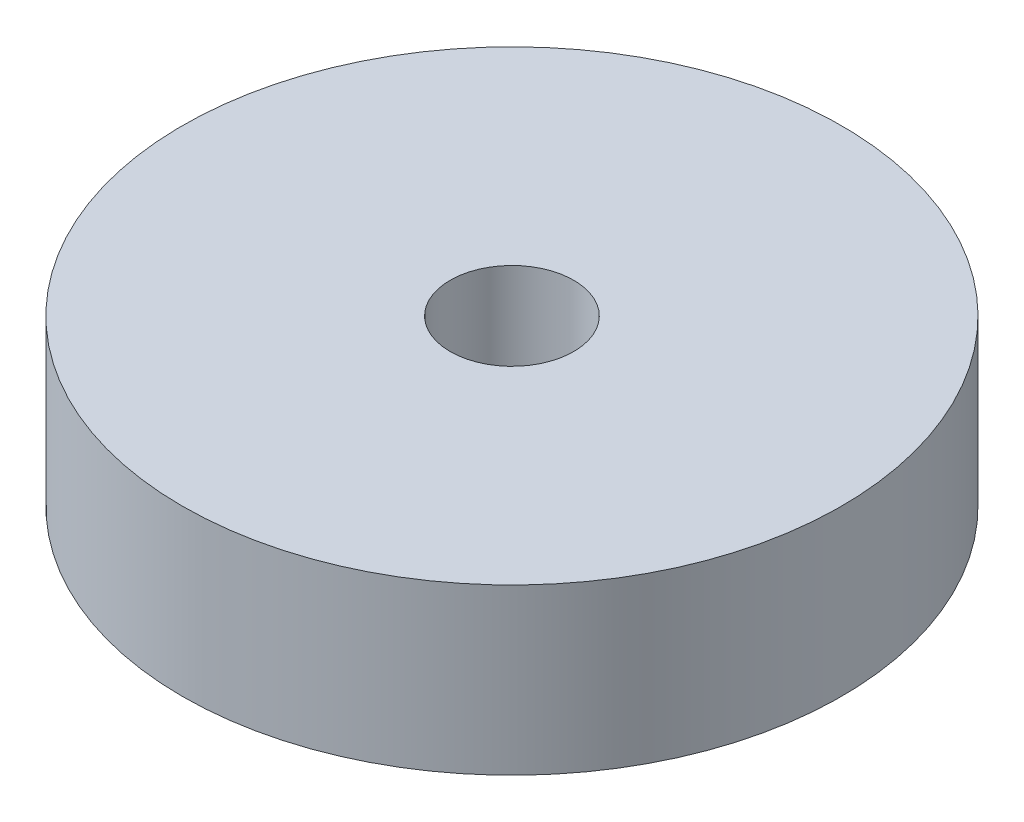
from build123d import *

# Parameters (mm, degrees)
SKETCH1_R               = 20
BOSS_EXTRUDE1_DEPTH     = 10
SKETCH2_R               = 3.75
CUT_EXTRUDE1_DEPTH      = 1
CUT_EXTRUDE1_DEPTH_BACK = 11


with BuildPart() as part:
    # Sketch1 → Boss-Extrude1 (new body)
    with BuildSketch(Plane(origin=(0, 0, 0), x_dir=(1, 0, 0), z_dir=(0, 1, 0))):
        Circle(SKETCH1_R)
    extrude(amount=BOSS_EXTRUDE1_DEPTH)

    # Sketch2 → Cut-Extrude1 (cut, two sides)
    with BuildSketch(Plane(origin=(0, 10, 0), x_dir=(1, 0, 0), z_dir=(0, 1, 0))) as cut_extrude1_sk:
        Circle(SKETCH2_R)
    extrude(amount=CUT_EXTRUDE1_DEPTH, mode=Mode.SUBTRACT)
    extrude(cut_extrude1_sk.sketch, amount=-CUT_EXTRUDE1_DEPTH_BACK, mode=Mode.SUBTRACT)


solid = part.part
